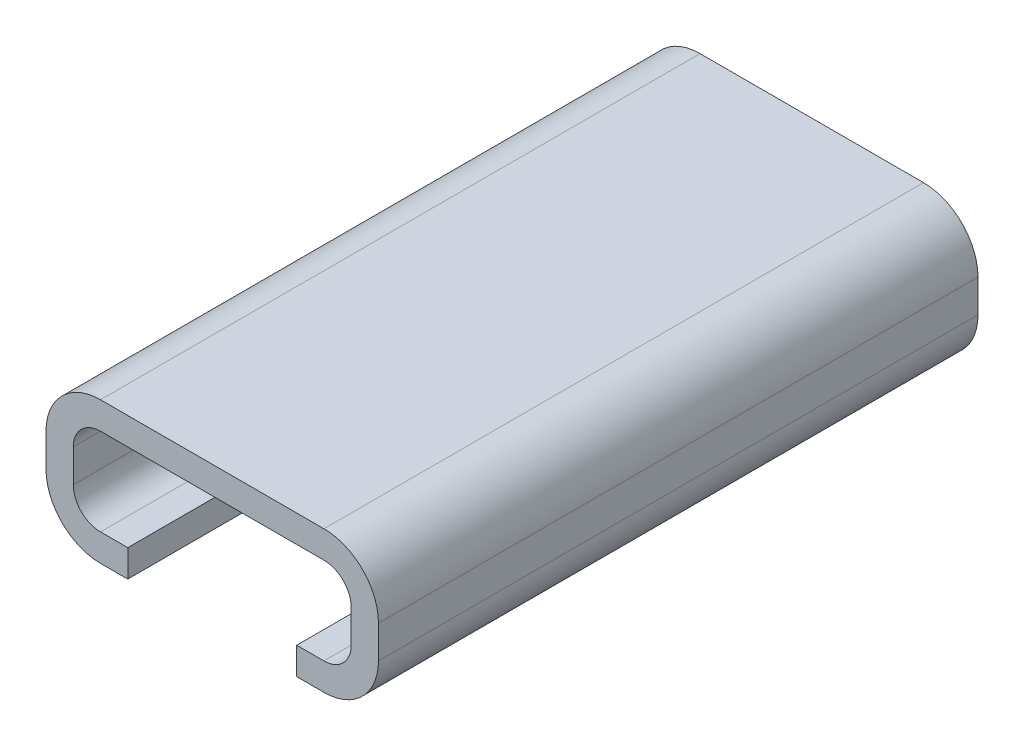
from build123d import *

# Parameters (mm, degrees)
BOSS_EXTRU_2_DEPTH      = 10
BOSS_EXTRU_4_DEPTH      = 1
ESQUISSE5_W             = 6.2
ESQUISSE5_H             = 10
ENL_V_MAT_EXTRU_1_DEPTH = 1


with BuildPart() as part:
    # Esquisse1 → Boss.-Extru.2 (new body)
    with BuildSketch(Plane.XY):
        with BuildLine():
            Line((6.1, -0.6), (6.1, 0.6))
            ThreePointArc((6.1, 0.6), (5.514213562, 2.014213562), (4.1, 2.6))
            Line((4.1, 2.6), (-2.332050808, 2.6))
            Line((-2.332050808, 2.6), (-4.1, 2.6))
            ThreePointArc((-4.1, 2.6), (-5.514213562, 2.014213562), (-6.1, 0.6))
            Line((-6.1, 0.6), (-6.1, -0.6))
            ThreePointArc((-6.1, -0.6), (-5.514213562, -2.014213562), (-4.1, -2.6))
            Line((-4.1, -2.6), (4.1, -2.6))
            ThreePointArc((4.1, -2.6), (5.514213562, -2.014213562), (6.1, -0.6))
        make_face()
        with BuildLine():
            ThreePointArc((4.1, 1.6), (4.807106781, 1.307106781), (5.1, 0.6))
            Line((5.1, 0.6), (5.1, -0.6))
            ThreePointArc((5.1, -0.6), (4.807106781, -1.307106781), (4.1, -1.6))
            Line((4.1, -1.6), (-4.1, -1.6))
            ThreePointArc((-4.1, -1.6), (-4.807106781, -1.307106781), (-5.1, -0.6))
            Line((-5.1, -0.6), (-5.1, 0.6))
            ThreePointArc((-5.1, 0.6), (-4.807106781, 1.307106781), (-4.1, 1.6))
            Line((-4.1, 1.6), (4.1, 1.6))
        make_face(mode=Mode.SUBTRACT)
    boss_extru_2 = extrude(amount=BOSS_EXTRU_2_DEPTH)

    # Esquisse7 → Boss.-Extru.4 (add)
    with BuildSketch(Plane(origin=(0, 0, 0), x_dir=(-1, 0, 0), z_dir=(0, 0, -1))):
        with BuildLine():
            Line((-6.1, 0.6), (-6.1, -0.6))
            ThreePointArc((-6.1, -0.6), (-5.514213562, -2.014213562), (-4.1, -2.6))
            Line((-4.1, -2.6), (4.1, -2.6))
            ThreePointArc((4.1, -2.6), (5.514213562, -2.014213562), (6.1, -0.6))
            Line((6.1, -0.6), (6.1, 0.6))
            ThreePointArc((6.1, 0.6), (5.514213562, 2.014213562), (4.1, 2.6))
            Line((4.1, 2.6), (-4.1, 2.6))
            ThreePointArc((-4.1, 2.6), (-5.514213562, 2.014213562), (-6.1, 0.6))
        make_face()
    boss_extru_4 = extrude(amount=BOSS_EXTRU_4_DEPTH)

    # Symétrie1: Boss.-Extru.2, Boss.-Extru.4 across plane
    add(boss_extru_2.mirror(Plane(origin=(4.1, 0.6, -1), x_dir=(1, 0, 0), z_dir=(0, 0, -1))))
    add(boss_extru_4.mirror(Plane(origin=(4.1, 0.6, -1), x_dir=(1, 0, 0), z_dir=(0, 0, -1))))

    # Esquisse5 → Enlèv. mat.-Extru.1 (cut)
    with BuildSketch(Plane.XZ.offset(2.6)):
        with Locations((0, -7)):
            Rectangle(ESQUISSE5_W, ESQUISSE5_H)
        with Locations((0, 5)):
            Rectangle(ESQUISSE5_W, ESQUISSE5_H)
    extrude(amount=-ENL_V_MAT_EXTRU_1_DEPTH, mode=Mode.SUBTRACT)


solid = part.part
